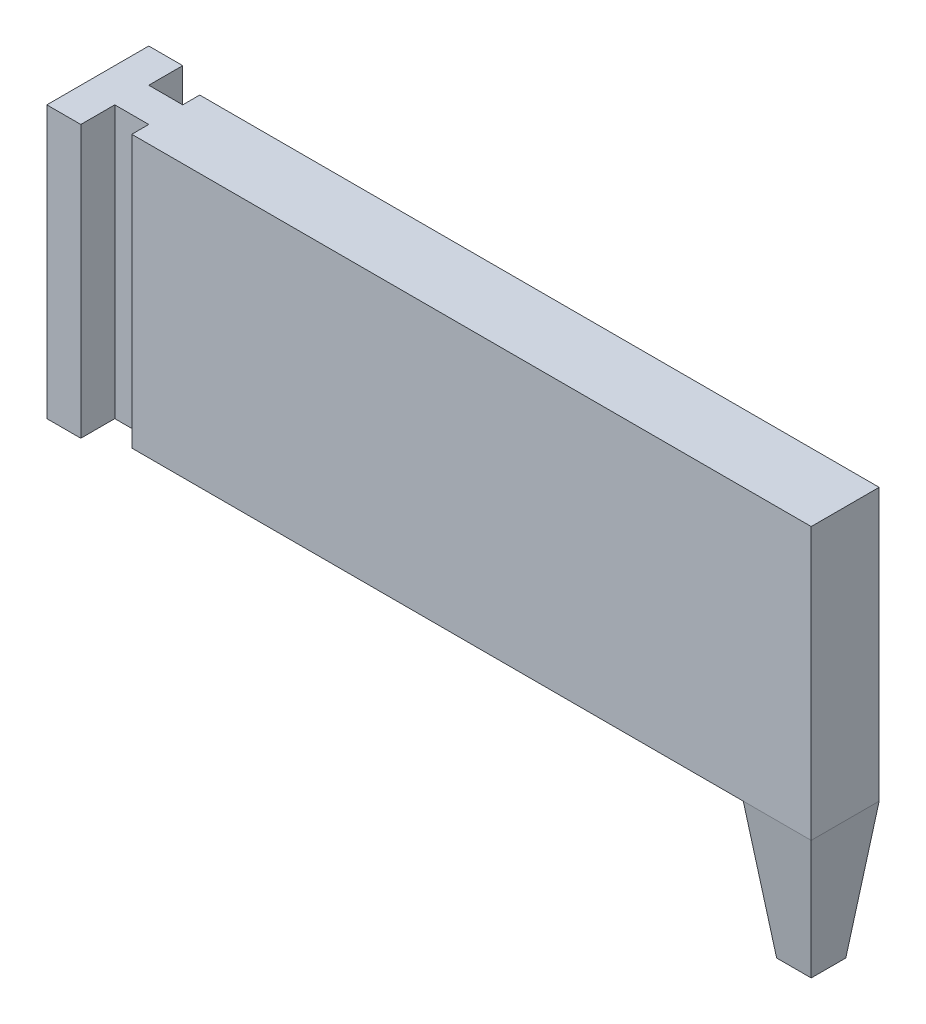
from build123d import *

# Parameters (mm, degrees)
BOSS_EXTRUDE1_DEPTH      = 40
SKETCH3_W                = 100
SKETCH3_H                = 40
BOSS_EXTRUDE2_DEPTH      = 5
BOSS_EXTRUDE2_DEPTH_BACK = 5
SKETCH4_W                = 10
SKETCH4_H                = 10
BOSS_EXTRUDE3_DEPTH      = 20
BOSS_EXTRUDE3_TAPER      = 7


with BuildPart() as part:
    # Sketch2 → Boss-Extrude1 (new body)
    with BuildSketch(Plane(origin=(0, 0, 0), x_dir=(1, 0, 0), z_dir=(0, 1, 0))):
        Polygon((-10, 7.5), (-10, -7.5), (-5, -7.5), (-5, -2.5), (0, -2.5), (0, 2.5), (-5, 2.5), (-5, 7.5), align=None)
    extrude(amount=BOSS_EXTRUDE1_DEPTH)

    # Sketch3 → Boss-Extrude2 (add, two sides)
    with BuildSketch(Plane.XY) as boss_extrude2_sk:
        with Locations((50, 20)):
            Rectangle(SKETCH3_W, SKETCH3_H)
    extrude(amount=BOSS_EXTRUDE2_DEPTH)
    extrude(boss_extrude2_sk.sketch, amount=-BOSS_EXTRUDE2_DEPTH_BACK)

    # Sketch4 → Boss-Extrude3 (add)
    with BuildSketch(Plane.XZ):
        with Locations((95, 0)):
            Rectangle(SKETCH4_W, SKETCH4_H)
    extrude(amount=BOSS_EXTRUDE3_DEPTH, taper=BOSS_EXTRUDE3_TAPER)


solid = part.part
